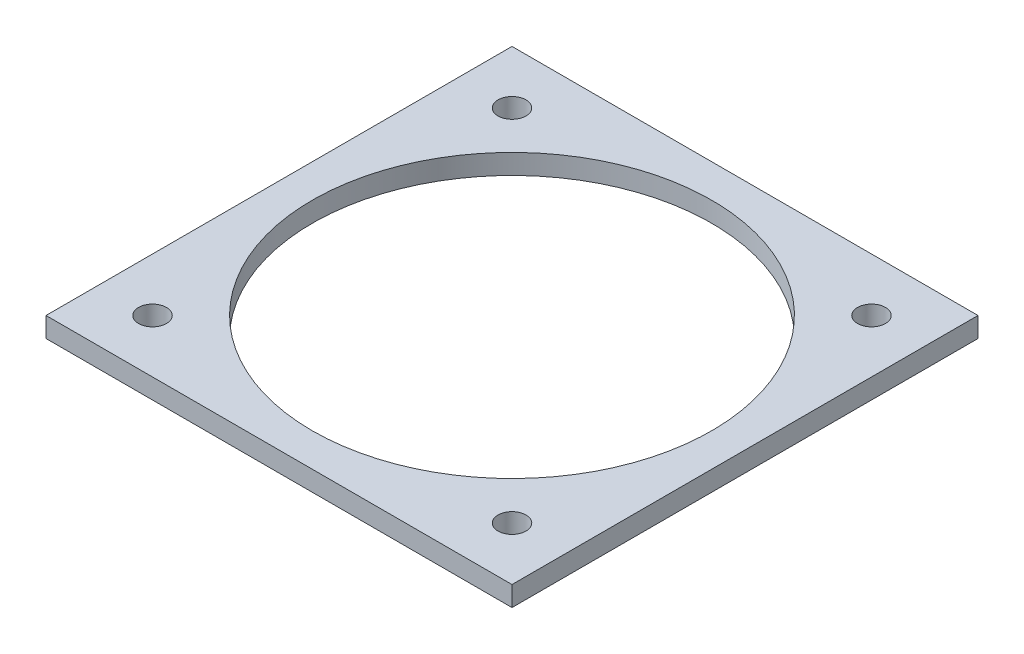
from build123d import *

# Parameters (mm, degrees)
SKETCH_1_W               = 70
SKETCH_1_H               = 70
SKETCH_1_R               = 30
EXTRUDE_1_DEPTH          = 3
SKETCH_2_R               = 2.1
CUT_EXTRUDE_1_DEPTH      = 10
PATTERN_CIRCULAR_1_COUNT = 4


with BuildPart() as part:
    # 草图1 → 凸台-拉伸1 (new body)
    with BuildSketch(Plane(origin=(0, 0, 0), x_dir=(1, 0, 0), z_dir=(0, 1, 0))):
        Rectangle(SKETCH_1_W, SKETCH_1_H)
        Circle(SKETCH_1_R, mode=Mode.SUBTRACT)
    extrude(amount=EXTRUDE_1_DEPTH)

    # 草图2 → 切除-拉伸1 (cut)
    with BuildSketch(Plane(origin=(0, 3, 0), x_dir=(1, 0, 0), z_dir=(0, 1, 0))):
        with Locations((27, 27)):
            Circle(SKETCH_2_R)
    cut_extrude_1 = extrude(amount=-CUT_EXTRUDE_1_DEPTH, mode=Mode.SUBTRACT)

    # 阵列(圆周)1: 切除-拉伸1 ×4 about axis
    pattern_circular_1_axis = Axis((0, 0, 0), (0, 1, 0))
    for i in range(1, PATTERN_CIRCULAR_1_COUNT):
        add(cut_extrude_1.rotate(pattern_circular_1_axis, i * 360 / PATTERN_CIRCULAR_1_COUNT), mode=Mode.SUBTRACT)


solid = part.part
